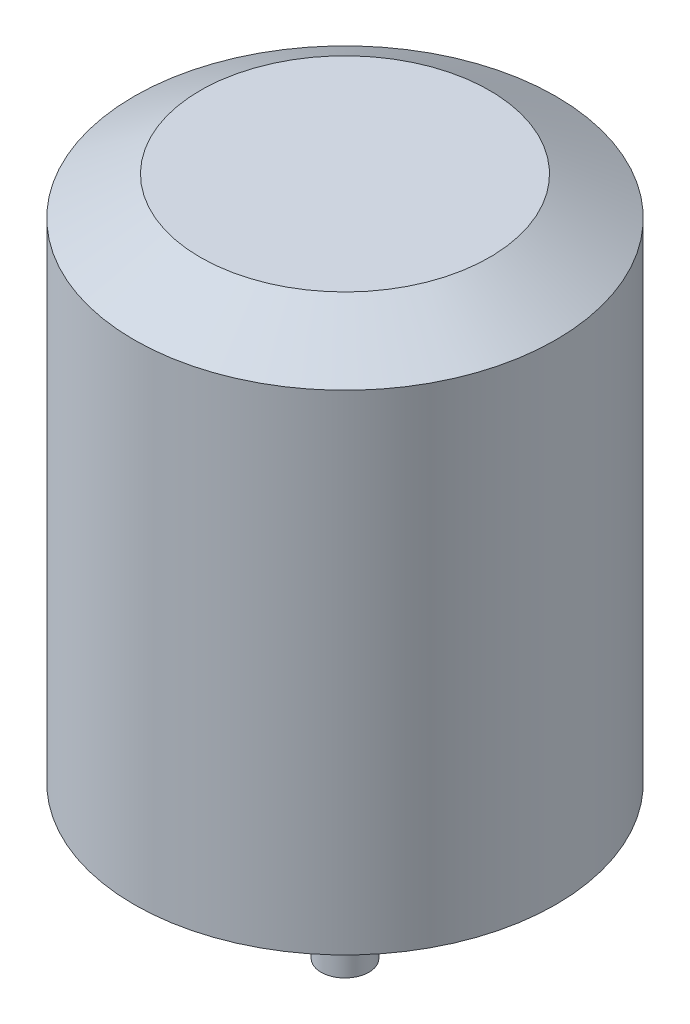
from build123d import *

# Parameters (mm, degrees)
SKETCH1_R           = 14
BOSS_EXTRUDE1_DEPTH = 17.5
CHAMFER1_SIZE       = 2.54
CHAMFER1_SIZE2      = 4.399409051
SKETCH2_R           = 1.5875
BOSS_EXTRUDE2_DEPTH = 10.1


with BuildPart() as part:
    # Sketch1 → Boss-Extrude1 (new body, symmetric)
    with BuildSketch(Plane(origin=(0, 0, 0), x_dir=(1, 0, 0), z_dir=(0, 1, 0))):
        Circle(SKETCH1_R)
    extrude(amount=BOSS_EXTRUDE1_DEPTH, both=True)

    # Chamfer1
    chamfer1_edges = [part.edges().sort_by_distance(p)[0] for p in [
        (-14, 17.5, 0),
    ]]
    chamfer1_side = [part.faces().sort_by_distance(p)[0] for p in [
        (-14, 0, 0),
    ]]
    chamfer(chamfer1_edges, length=CHAMFER1_SIZE, length2=CHAMFER1_SIZE2, reference=chamfer1_side[0])

    # Sketch2 → Boss-Extrude2 (add)
    with BuildSketch(Plane.XZ.offset(17.5)):
        Circle(SKETCH2_R)
    extrude(amount=BOSS_EXTRUDE2_DEPTH)


solid = part.part
